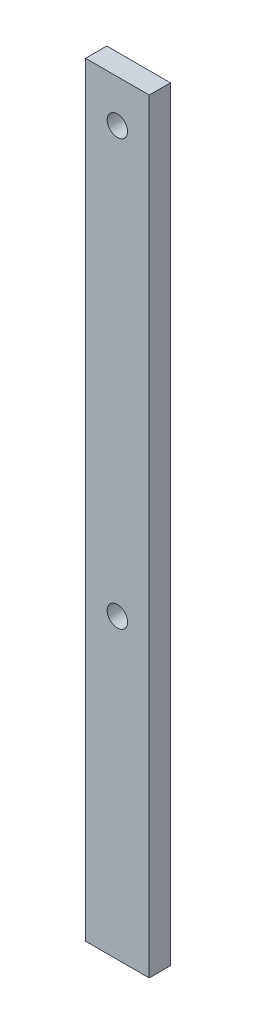
from build123d import *

# Parameters (mm, degrees)
SKETCH1_W           = 19.05
SKETCH1_H           = 228.6
BOSS_EXTRUDE1_DEPTH = 6.35
SKETCH2_R           = 3.048
CUT_EXTRUDE1_DEPTH  = 6.35


with BuildPart() as part:
    # Sketch1 → Boss-Extrude1 (new body)
    with BuildSketch(Plane.XY):
        with Locations((9.525, 114.3)):
            Rectangle(SKETCH1_W, SKETCH1_H)
    extrude(amount=BOSS_EXTRUDE1_DEPTH)

    # Sketch2 → Cut-Extrude1 (cut)
    with BuildSketch(Plane.XY.offset(6.35)):
        with Locations((9.525, 215.9)):
            Circle(SKETCH2_R)
        with Locations((9.525, 88.9)):
            Circle(SKETCH2_R)
    extrude(amount=-CUT_EXTRUDE1_DEPTH, mode=Mode.SUBTRACT)


solid = part.part
